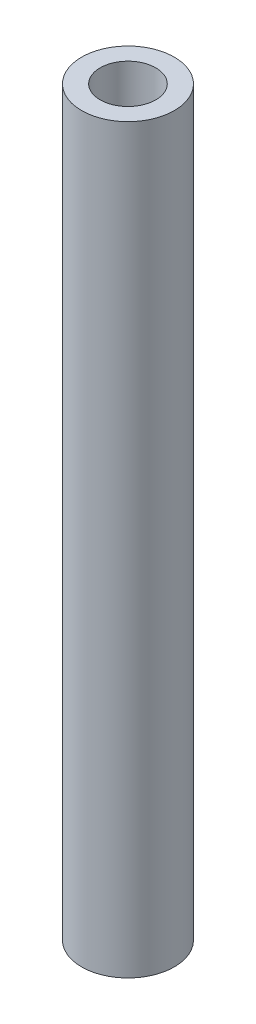
from build123d import *

# Parameters (mm, degrees)
SKETCH_1_R      = 2.5
SKETCH_1_R_2    = 1.5
EXTRUDE_1_DEPTH = 40


with BuildPart() as part:
    # 草图1 → 凸台-拉伸1 (new body)
    with BuildSketch(Plane(origin=(0, 0, 0), x_dir=(1, 0, 0), z_dir=(0, 1, 0))):
        Circle(SKETCH_1_R)
        Circle(SKETCH_1_R_2, mode=Mode.SUBTRACT)
    extrude(amount=EXTRUDE_1_DEPTH)


solid = part.part
